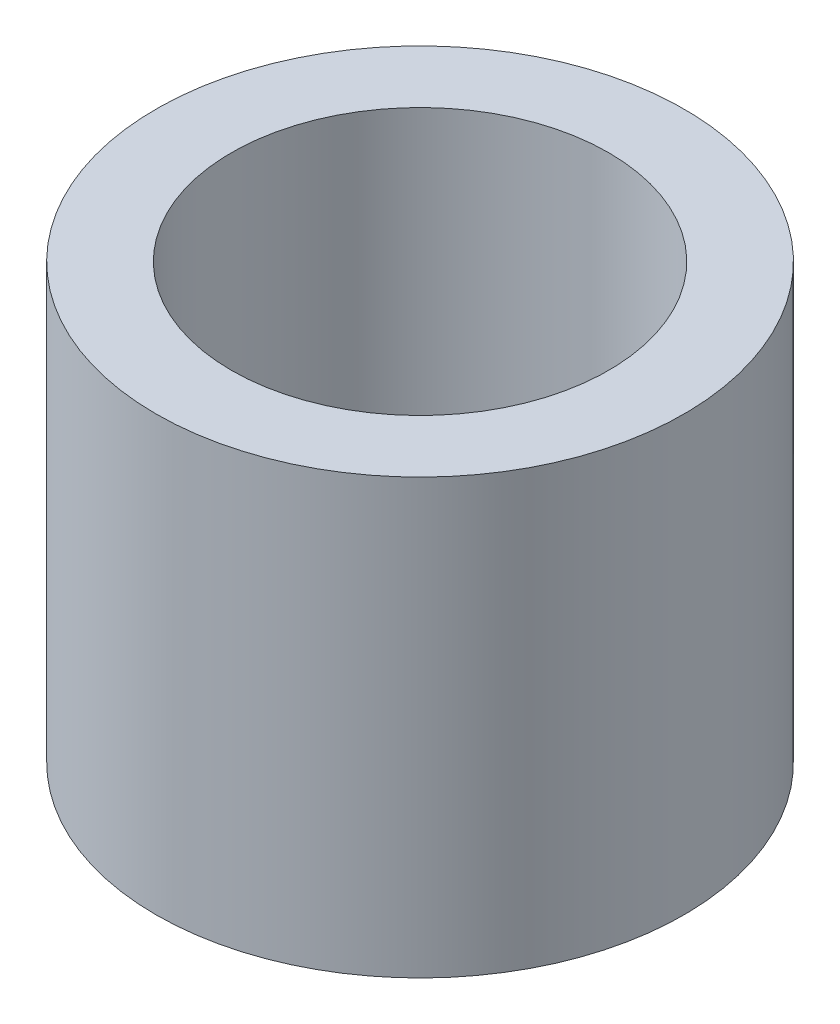
from build123d import *

# Parameters (mm, degrees)
SKETCH3_R           = 44.45
SKETCH3_R_2         = 31.75
BOSS_EXTRUDE1_DEPTH = 73.025


with BuildPart() as part:
    # Sketch3 → Boss-Extrude1 (new body)
    with BuildSketch(Plane(origin=(0, 0, 0), x_dir=(1, 0, 0), z_dir=(0, 1, 0))):
        Circle(SKETCH3_R)
        Circle(SKETCH3_R_2, mode=Mode.SUBTRACT)
    extrude(amount=BOSS_EXTRUDE1_DEPTH)


solid = part.part
